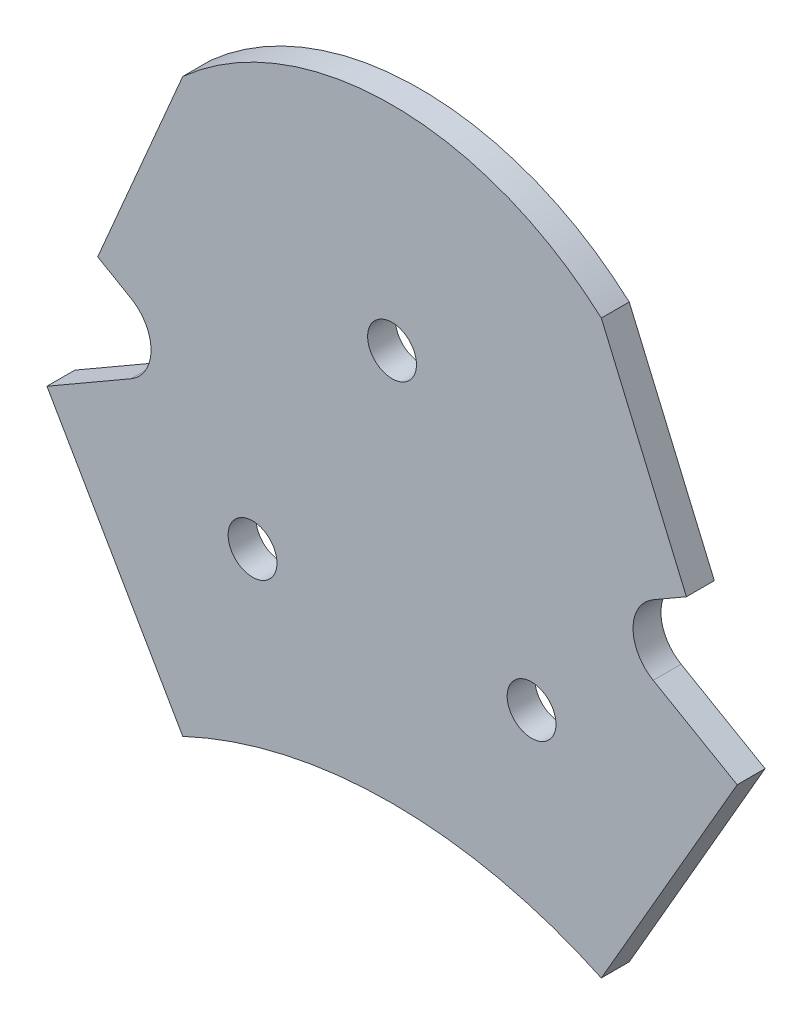
from build123d import *

# Parameters (mm, degrees)
SKETCH1_R           = 3.5
BOSS_EXTRUDE1_DEPTH = 4


with BuildPart() as part:
    # Sketch1 → Boss-Extrude1 (new body)
    with BuildSketch(Plane.XY):
        with BuildLine():
            Line((-30, -39.805989232), (-49.472997898, -6.077767497))
            Line((-49.472997898, -6.077767497), (-37.435244785, 0.872232503))
            ThreePointArc((-37.435244785, 0.872232503), (-34.548493439, 5.872232503), (-37.435244785, 10.872232503))
            Line((-37.435244785, 10.872232503), (-42.198384506, 13.622232503))
            Line((-42.198384506, 13.622232503), (-30, 42.12134504))
            ThreePointArc((-30, 42.12134504), (0, 53.594010768), (30, 42.12134504))
            Line((30, 42.12134504), (42.198384506, 13.622232503))
            Line((42.198384506, 13.622232503), (37.435244785, 10.872232503))
            ThreePointArc((37.435244785, 10.872232503), (34.548493439, 5.872232503), (37.435244785, 0.872232503))
            Line((37.435244785, 0.872232503), (49.472997898, -6.077767497))
            Line((49.472997898, -6.077767497), (30, -39.805989232))
            ThreePointArc((30, -39.805989232), (0, -33.105989232), (-30, -39.805989232))
        make_face()
        with Locations((0, 23.094010768)):
            Circle(SKETCH1_R, mode=Mode.SUBTRACT)
        with Locations((-20, -11.547005384)):
            Circle(SKETCH1_R, mode=Mode.SUBTRACT)
        with Locations((20, -11.547005384)):
            Circle(SKETCH1_R, mode=Mode.SUBTRACT)
    extrude(amount=BOSS_EXTRUDE1_DEPTH)


solid = part.part
